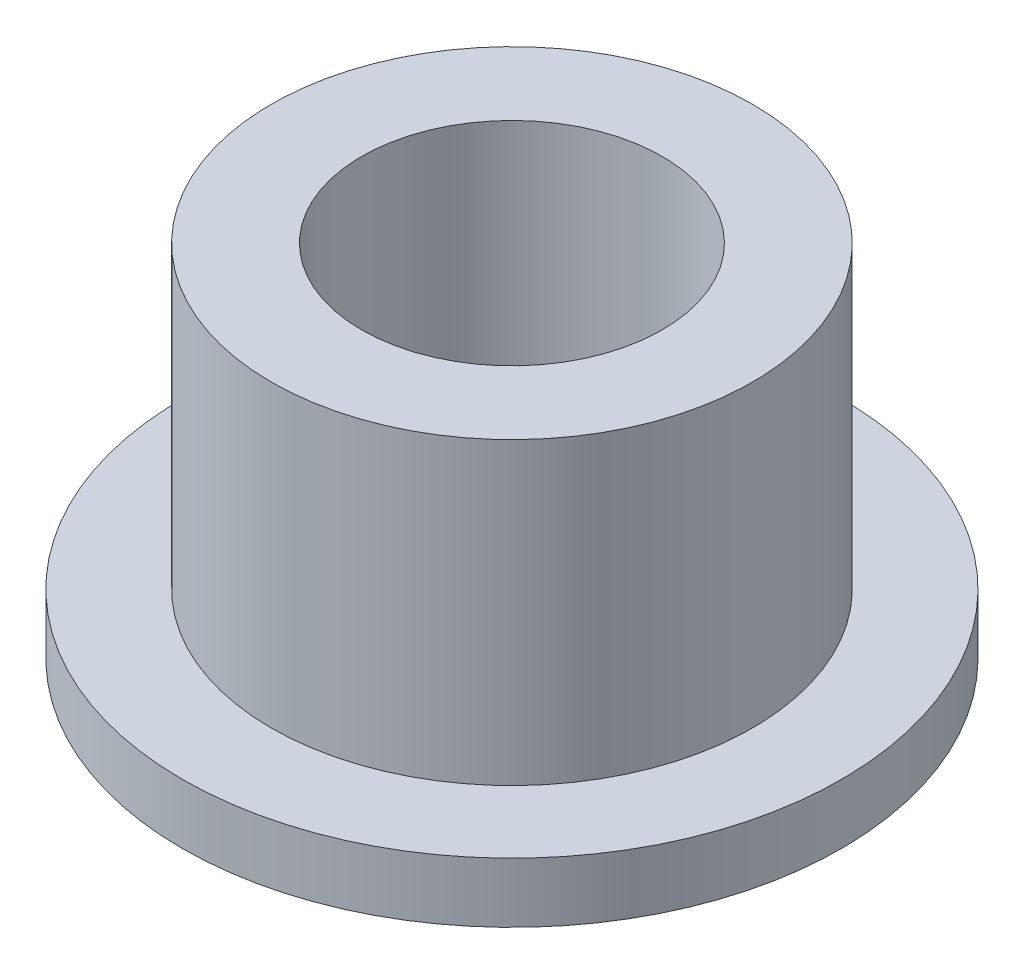
from build123d import *

# Parameters (mm, degrees)
SKETCH2_R           = 6.3754
SKETCH2_R_2         = 3.98145
BOSS_EXTRUDE1_DEPTH = 9.525
SKETCH3_R           = 8.73125
SKETCH3_R_2         = 6.3754
BOSS_EXTRUDE2_DEPTH = 1.5875


with BuildPart() as part:
    # Sketch2 → Boss-Extrude1 (new body)
    with BuildSketch(Plane(origin=(0, 0, 0), x_dir=(1, 0, 0), z_dir=(0, 1, 0))):
        Circle(SKETCH2_R)
        Circle(SKETCH2_R_2, mode=Mode.SUBTRACT)
    extrude(amount=BOSS_EXTRUDE1_DEPTH)

    # Sketch3 → Boss-Extrude2 (add)
    with BuildSketch(Plane(origin=(0, 0, 0), x_dir=(1, 0, 0), z_dir=(0, 1, 0))):
        Circle(SKETCH3_R)
        Circle(SKETCH3_R_2, mode=Mode.SUBTRACT)
    extrude(amount=BOSS_EXTRUDE2_DEPTH)


solid = part.part
